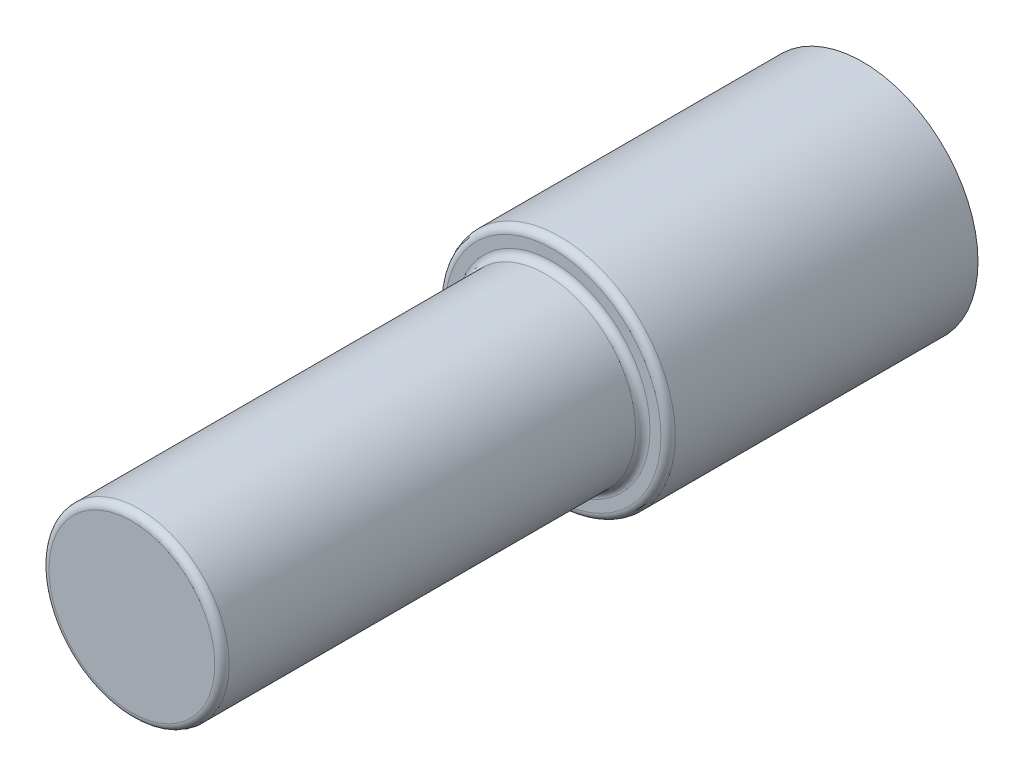
from build123d import *

# Parameters (mm, degrees)
SKETCH1_R                 = 16
BOSS_EXTRUDE1_DEPTH       = 43
SKETCH2_R                 = 12.5
BOSS_EXTRUDE2_DEPTH       = 58.4
SKETCH3_R                 = 9.5
BOSS_EXTRUDE3_DEPTH       = 2.25
SKETCH4_R                 = 5
BOSS_EXTRUDE4_DEPTH       = 2.6
SKETCH5_R                 = 3
CUT_EXTRUDE1_DEPTH        = 5
FILLET1_R                 = 1
M3X0_5_TAPPED_HOLE1_D     = 2.5
M3X0_5_TAPPED_HOLE1_DEPTH = 6.3
M3X0_5_TAPPED_HOLE1_TIP   = 0.751075774


with BuildPart() as part:
    # Sketch1 → Boss-Extrude1 (new body)
    with BuildSketch(Plane.XY):
        Circle(SKETCH1_R)
    extrude(amount=BOSS_EXTRUDE1_DEPTH)

    # Sketch2 → Boss-Extrude2 (add)
    with BuildSketch(Plane.XY.offset(43)):
        Circle(SKETCH2_R)
    extrude(amount=BOSS_EXTRUDE2_DEPTH)

    # Sketch3 → Boss-Extrude3 (add)
    with BuildSketch(Plane(origin=(0, 0, 0), x_dir=(-1, 0, 0), z_dir=(0, 0, -1))):
        Circle(SKETCH3_R)
    extrude(amount=BOSS_EXTRUDE3_DEPTH)

    # Sketch4 → Boss-Extrude4 (add)
    with BuildSketch(Plane(origin=(0, 0, -2.25), x_dir=(-1, 0, 0), z_dir=(0, 0, -1))):
        Circle(SKETCH4_R)
    extrude(amount=BOSS_EXTRUDE4_DEPTH)

    # Sketch5 → Cut-Extrude1 (cut)
    with BuildSketch(Plane(origin=(0, 0, -4.85), x_dir=(-1, 0, 0), z_dir=(0, 0, -1))):
        Circle(SKETCH5_R)
    extrude(amount=-CUT_EXTRUDE1_DEPTH, mode=Mode.SUBTRACT)

    # Fillet1
    fillet1_edges = [part.edges().sort_by_distance(p)[0] for p in [
        (-16, 0, 43),
        (-12.5, 0, 43),
        (-12.5, 0, 101.4),
    ]]
    fillet(fillet1_edges, radius=FILLET1_R)

    # M3x0.5 Tapped Hole1
    with Locations(Plane(origin=(0, 0, 0), x_dir=(-1, 0, 0), z_dir=(0, 0, -1))):
        with Locations((0, 13), (-13, 0), (0, -13), (13, 0)):
            Hole(M3X0_5_TAPPED_HOLE1_D / 2, depth=M3X0_5_TAPPED_HOLE1_DEPTH)
            with Locations((0, 0, -(M3X0_5_TAPPED_HOLE1_DEPTH + M3X0_5_TAPPED_HOLE1_TIP / 2))):  # 118° drill point
                Cone(0, M3X0_5_TAPPED_HOLE1_D / 2, M3X0_5_TAPPED_HOLE1_TIP, mode=Mode.SUBTRACT)


solid = part.part
